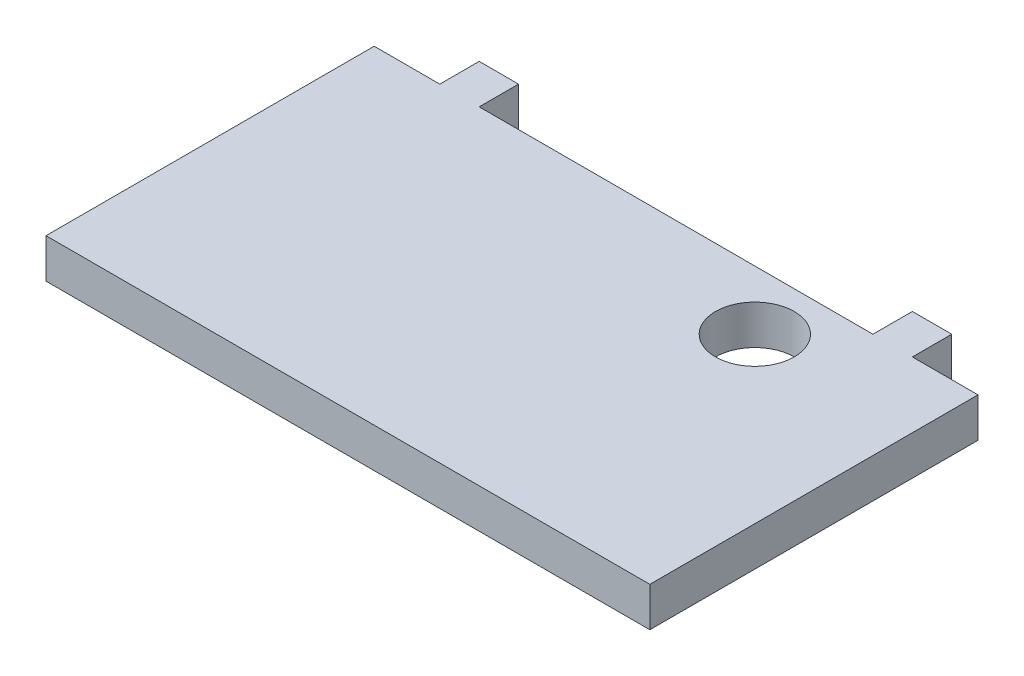
from build123d import *

# Parameters (mm, degrees)
SKETCH1_W           = 92
SKETCH1_H           = 6
BOSS_EXTRUDE1_DEPTH = 50
SKETCH2_W           = 6
SKETCH2_H           = 6
BOSS_EXTRUDE2_DEPTH = 6
SKETCH3_R           = 6
CUT_EXTRUDE1_DEPTH  = 6


with BuildPart() as part:
    # Sketch1 → Boss-Extrude1 (new body)
    with BuildSketch(Plane.XY):
        with Locations((0, 3)):
            Rectangle(SKETCH1_W, SKETCH1_H)
    extrude(amount=BOSS_EXTRUDE1_DEPTH)

    # Sketch2 → Boss-Extrude2 (add)
    with BuildSketch(Plane(origin=(0, 0, 0), x_dir=(-1, 0, 0), z_dir=(0, 0, -1))):
        with Locations((-33, 3)):
            Rectangle(SKETCH2_W, SKETCH2_H)
        with Locations((33, 3)):
            Rectangle(SKETCH2_W, SKETCH2_H)
    extrude(amount=BOSS_EXTRUDE2_DEPTH)

    # Sketch3 → Cut-Extrude1 (cut)
    with BuildSketch(Plane.XZ):
        with Locations((21, 9)):
            Circle(SKETCH3_R)
    extrude(amount=-CUT_EXTRUDE1_DEPTH, mode=Mode.SUBTRACT)


solid = part.part
